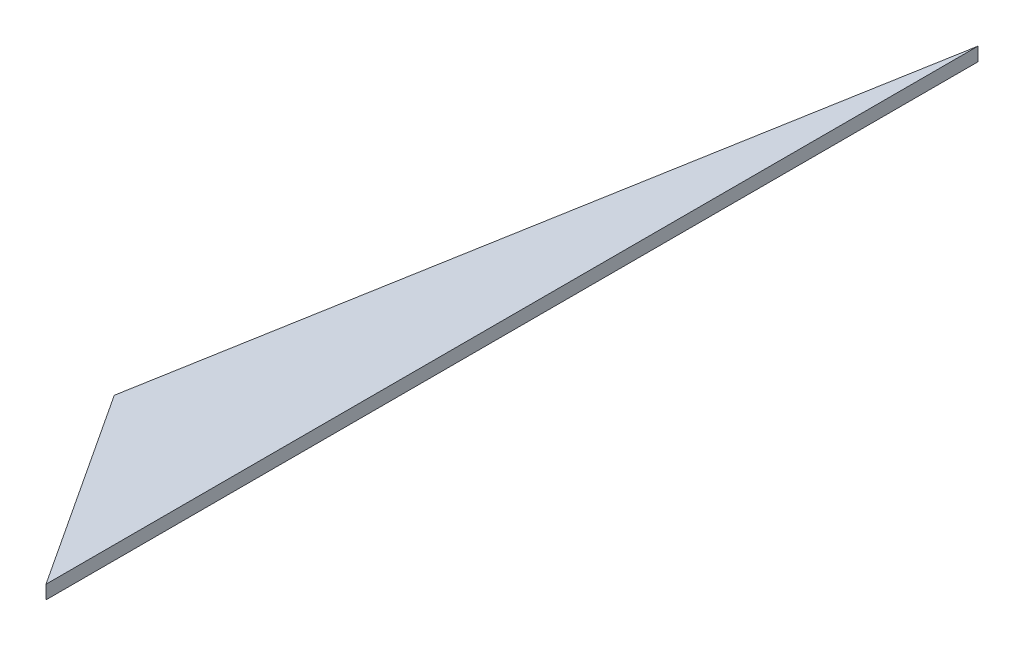
from build123d import *

# Parameters (mm, degrees)
BOSS_EXTRUDE1_DEPTH = 88.9


with BuildPart() as part:
    # Sketch1 → Boss-Extrude1 (new body)
    with BuildSketch(Plane(origin=(0, 0, 0), x_dir=(1, 0, 0), z_dir=(0, 1, 0))):
        Polygon((0, 0), (0, 6096), (-846.847432846, 1293.28955011), align=None)
    extrude(amount=BOSS_EXTRUDE1_DEPTH)


solid = part.part
